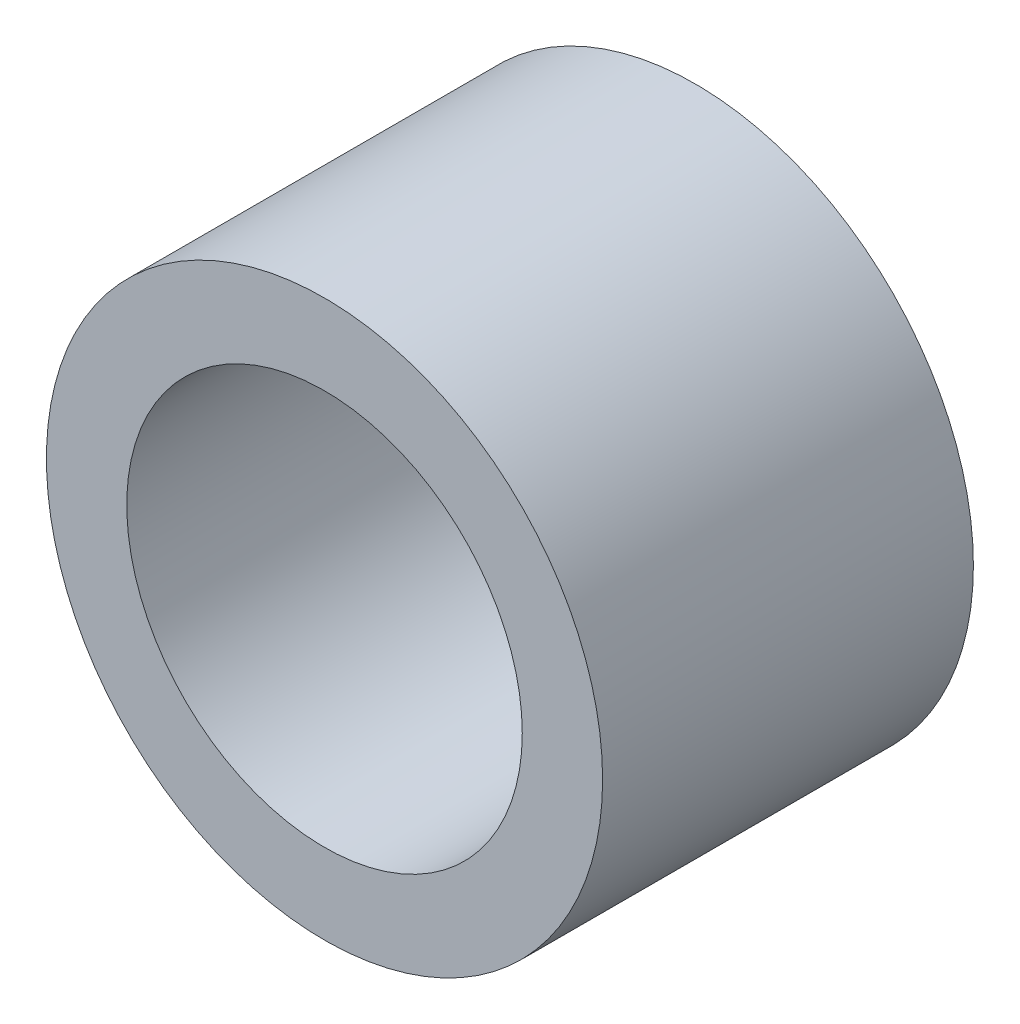
from build123d import *

# Parameters (mm, degrees)
SKETCH1_R           = 2.25
SKETCH1_R_2         = 1.6
EXTRUDE1_DEPTH      = 1.5
EXTRUDE1_DEPTH_BACK = 1.5


with BuildPart() as part:
    # Sketch1 → Extrude1 (new body, two sides)
    with BuildSketch(Plane.XY) as extrude1_sk:
        Circle(SKETCH1_R)
        Circle(SKETCH1_R_2, mode=Mode.SUBTRACT)
    extrude(amount=EXTRUDE1_DEPTH)
    extrude(extrude1_sk.sketch, amount=-EXTRUDE1_DEPTH_BACK)


solid = part.part
